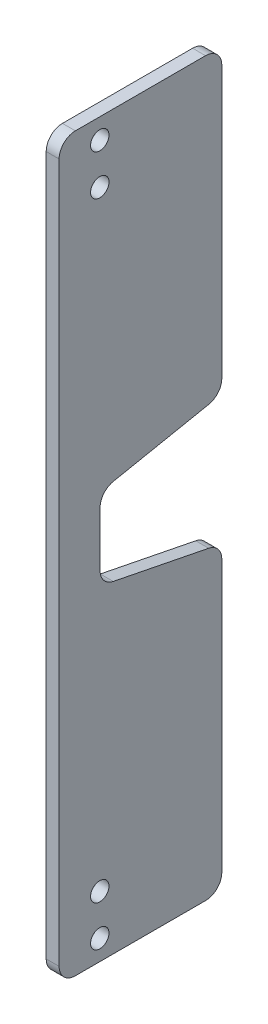
from build123d import *

# Parameters (mm, degrees)
SKETCH_1_R      = 1.1303
EXTRUDE_1_DEPTH = 1.588
FILLET_1_R      = 2
FILLET_2_R      = 2
FILLET_3_R      = 2
FILLET_4_R      = 2


with BuildPart() as part:
    # 草图1 → 凸台-拉伸1 (new body)
    with BuildSketch(Plane(origin=(-0.79375, 0, 0), x_dir=(0, -1, 0), z_dir=(-1, 0, 0))):
        with BuildLine():
            Line((38.795, 5), (12.795, 5))
            ThreePointArc((12.795, 5), (11.380786438, 4.414213562), (10.795, 3))
            Line((10.795, 3), (10.795, -13))
            ThreePointArc((10.795, -13), (11.380786438, -14.414213562), (12.795, -15))
            Line((12.795, -15), (47.795, -15))
            Line((47.795, -15), (50.77, -0.039144756))
            Line((50.77, -0.039144756), (55.77, -0.039144756))
            Line((55.77, -0.039144756), (60.77, -0.039144756))
            Line((60.77, -0.039144756), (63.745, -15))
            Line((63.745, -15), (98.745, -15))
            ThreePointArc((98.745, -15), (100.159213562, -14.414213562), (100.745, -13))
            Line((100.745, -13), (100.745, 3))
            ThreePointArc((100.745, 3), (100.159213562, 4.414213562), (98.745, 5))
            Line((98.745, 5), (72.745, 5))
            Line((72.745, 5), (38.795, 5))
        make_face()
        with Locations((18.295, 0)):
            Circle(SKETCH_1_R, mode=Mode.SUBTRACT)
        with Locations((13.295, 0)):
            Circle(SKETCH_1_R, mode=Mode.SUBTRACT)
        with Locations((98.245, 0)):
            Circle(SKETCH_1_R, mode=Mode.SUBTRACT)
        with Locations((93.245, 0)):
            Circle(SKETCH_1_R, mode=Mode.SUBTRACT)
    extrude(amount=-EXTRUDE_1_DEPTH)

    # 圆角1
    fillet_1_edges = [part.edges().sort_by_distance(p)[0] for p in [
        (0.00025, -50.77, -0.039144756),
    ]]
    fillet(fillet_1_edges, radius=FILLET_1_R)

    # 圆角2
    fillet_2_edges = [part.edges().sort_by_distance(p)[0] for p in [
        (0.00025, -47.795, -15),
    ]]
    fillet(fillet_2_edges, radius=FILLET_2_R)

    # 圆角3
    fillet_3_edges = [part.edges().sort_by_distance(p)[0] for p in [
        (0.00025, -60.77, -0.039144756),
    ]]
    fillet(fillet_3_edges, radius=FILLET_3_R)

    # 圆角4
    fillet_4_edges = [part.edges().sort_by_distance(p)[0] for p in [
        (0.00025, -63.745, -15),
    ]]
    fillet(fillet_4_edges, radius=FILLET_4_R)


solid = part.part
